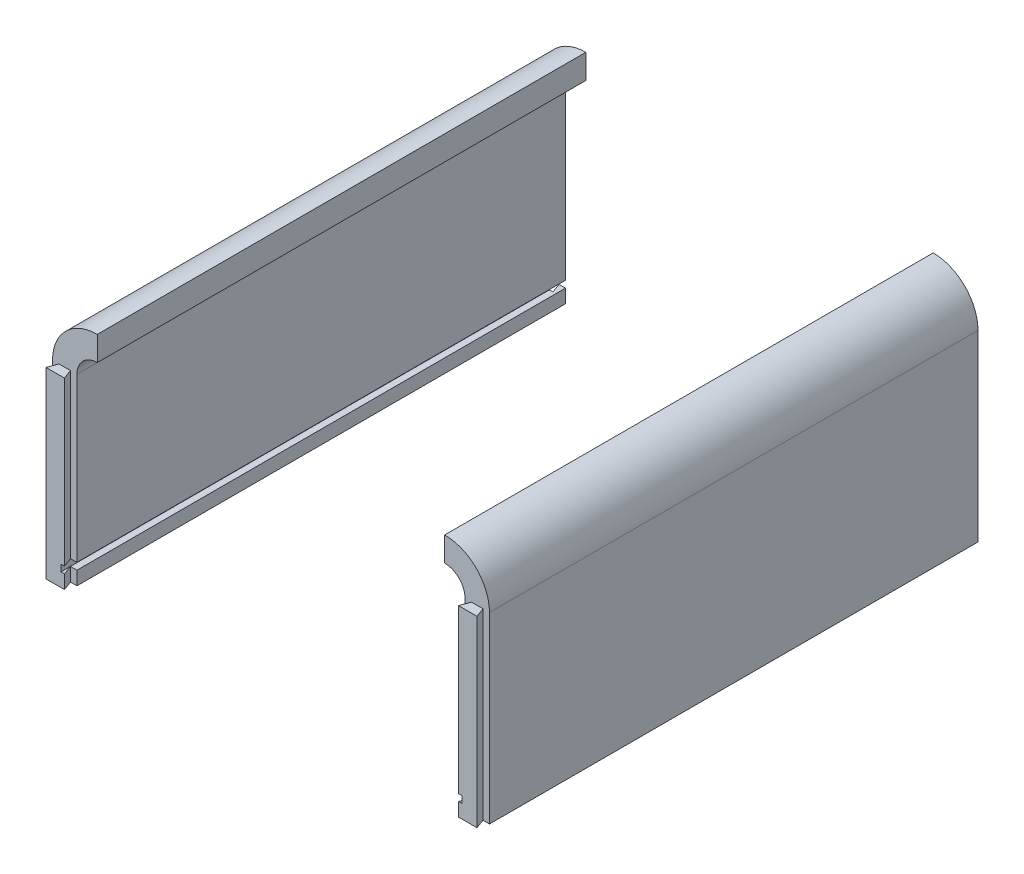
from build123d import *

# Parameters (mm, degrees)
EXTRUDE_4_DEPTH     = 72
EXTRUDE_4_2_DEPTH   = 72
EXTRUDE_5_DEPTH     = 27
SKETCH_4_W          = 0.519558328
SKETCH_4_H          = 1
CUT_EXTRUDE_2_DEPTH = 1.4
CUT_EXTRUDE_4_DEPTH = 27


with BuildPart() as part:
    # 草圖1 → 填料-伸長4 (new body)
    with BuildSketch(Plane.XY):
        with BuildLine():
            Line((28.6, -25.24895757), (28.6, -49.24895757))
            Line((28.6, -49.24895757), (29.56, -49.24895757))
            Line((29.56, -49.24895757), (29.56, -50.24895757))
            Line((29.56, -50.24895757), (28.6, -50.24895757))
            Line((28.6, -50.24895757), (28.6, -52.24895757))
            Line((28.6, -52.24895757), (32.2, -52.24895757))
            Line((32.2, -52.24895757), (32.2, -25.24895757))
            ThreePointArc((32.2, -25.24895757), (30.266904756, -20.582052814), (25.6, -18.64895757))
            Line((25.6, -18.64895757), (25.6, -22.24895757))
            ThreePointArc((25.6, -22.24895757), (27.721320344, -23.127637226), (28.6, -25.24895757))
        make_face()
    extrude(amount=EXTRUDE_4_DEPTH)



with BuildPart() as body_2:
    # 草圖1 → Extrude 4 2 (new body)
    with BuildSketch(Plane.XY):
        with BuildLine():
            Line((-25.6, -22.24895757), (-25.6, -18.64895757))
            ThreePointArc((-25.6, -18.64895757), (-30.266904756, -20.582052814), (-32.2, -25.24895757))
            Line((-32.2, -25.24895757), (-32.2, -52.24895757))
            Line((-32.2, -52.24895757), (-28.6, -52.24895757))
            Line((-28.6, -52.24895757), (-28.6, -50.24895757))
            Line((-28.6, -50.24895757), (-29.56, -50.24895757))
            Line((-29.56, -50.24895757), (-29.56, -49.24895757))
            Line((-29.56, -49.24895757), (-28.6, -49.24895757))
            Line((-28.6, -49.24895757), (-28.6, -25.24895757))
            ThreePointArc((-28.6, -25.24895757), (-27.721320344, -23.127637226), (-25.6, -22.24895757))
        make_face()
    extrude(amount=EXTRUDE_4_2_DEPTH)


with BuildPart() as part_1:
    add(part.part)

    add(body_2.part)  # 填料-伸長5 merges body 2
    # 草圖3 → 填料-伸長5 (add)
    with BuildSketch(Plane.XZ.offset(52.24895757)):
        Polygon((-31.25, 72), (-31.759558328, 73.4), (-29.040441672, 73.4), (-29.55, 72), align=None)
        Polygon((29.55, 72), (29.040441672, 73.4), (31.759558328, 73.4), (31.25, 72), align=None)
    extrude(amount=-EXTRUDE_5_DEPTH)

    # 草圖4 → 除料-伸長2 (cut)
    with BuildSketch(Plane.XY.offset(73.4)):
        with Locations((-29.300220836, -49.74895757)):
            Rectangle(SKETCH_4_W, SKETCH_4_H)
        with Locations((29.300220836, -49.74895757)):
            Rectangle(SKETCH_4_W, SKETCH_4_H)
    extrude(amount=-CUT_EXTRUDE_2_DEPTH, mode=Mode.SUBTRACT)

    # 草圖5 → 除料-伸長4 (cut)
    with BuildSketch(Plane.XZ.offset(52.24895757)):
        Polygon((-31.25, 0), (-31.759558328, 1.4), (-29.040441672, 1.4), (-29.55, 0), align=None)
        Polygon((29.55, 0), (29.040441672, 1.4), (31.759558328, 1.4), (31.25, 0), align=None)
    extrude(amount=-CUT_EXTRUDE_4_DEPTH, mode=Mode.SUBTRACT)


solid = part_1.part
